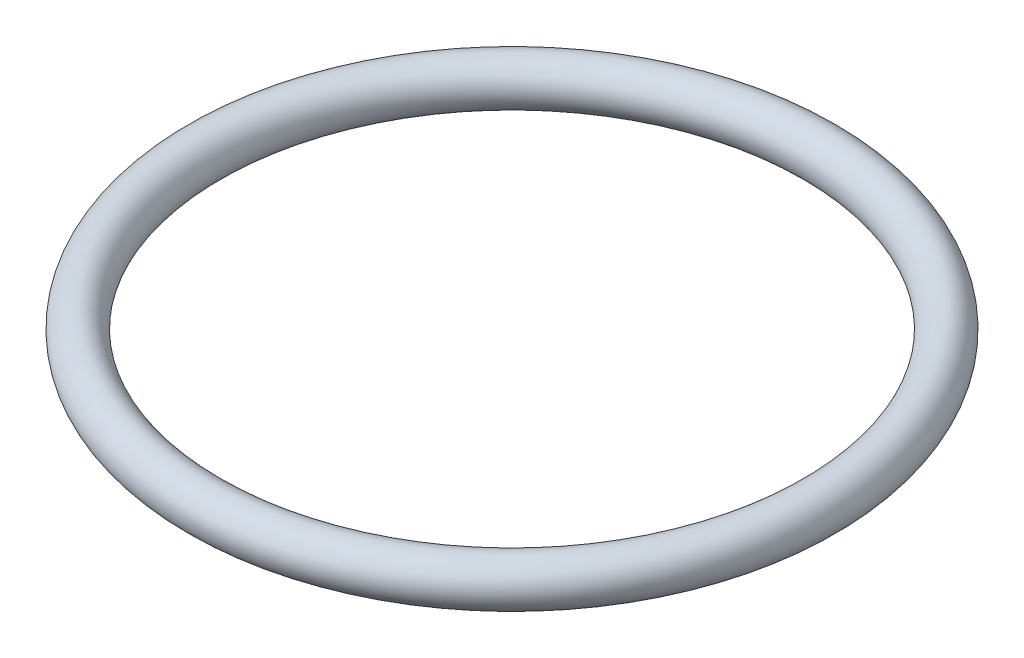
from build123d import *

# Parameters (mm, degrees)
SKETCH2_R = 0.75


with BuildPart() as part:
    # Sketch2 → Revolve1 (revolve)
    with BuildSketch(Plane.XY):
        with Locations((-10.25, 0)):
            Circle(SKETCH2_R)
    revolve(axis=Axis((0, 0, 0), (0, 1, 0)))


solid = part.part
